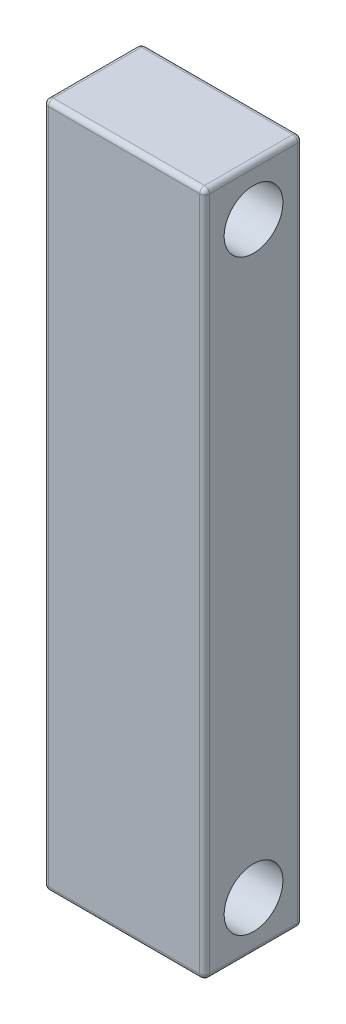
from build123d import *

# Parameters (mm, degrees)
SKETCH1_W           = 32.9
SKETCH1_H           = 140
BOSS_EXTRUDE1_DEPTH = 20
SKETCH3_R           = 6
CUT_EXTRUDE1_DEPTH  = 33.9
FILLET1_R           = 1


with BuildPart() as part:
    # Sketch1 → Boss-Extrude1 (new body)
    with BuildSketch(Plane.XY):
        Rectangle(SKETCH1_W, SKETCH1_H)
    extrude(amount=BOSS_EXTRUDE1_DEPTH)

    # Sketch3 → Cut-Extrude1 (cut, through all)
    with BuildSketch(Plane(origin=(16.45, 0, 0), x_dir=(0, 0, -1), z_dir=(1, 0, 0))):
        with Locations((-10, 60)):
            Circle(SKETCH3_R)
        with Locations((-10, -60)):
            Circle(SKETCH3_R)
    extrude(amount=-CUT_EXTRUDE1_DEPTH, mode=Mode.SUBTRACT)

    # Fillet1
    fillet1_edges = [part.edges().sort_by_distance(p)[0] for p in [
        (-16.45, 0, 20),
        (0, -70, 20),
        (16.45, 0, 20),
        (0, -70, 0),
        (-16.45, 0, 0),
        (0, 70, 0),
        (16.45, 0, 0),
        (0, 70, 20),
        (16.45, -70, 10),
        (-16.45, -70, 10),
        (-16.45, 70, 10),
        (16.45, 70, 10),
    ]]
    fillet(fillet1_edges, radius=FILLET1_R)


solid = part.part
